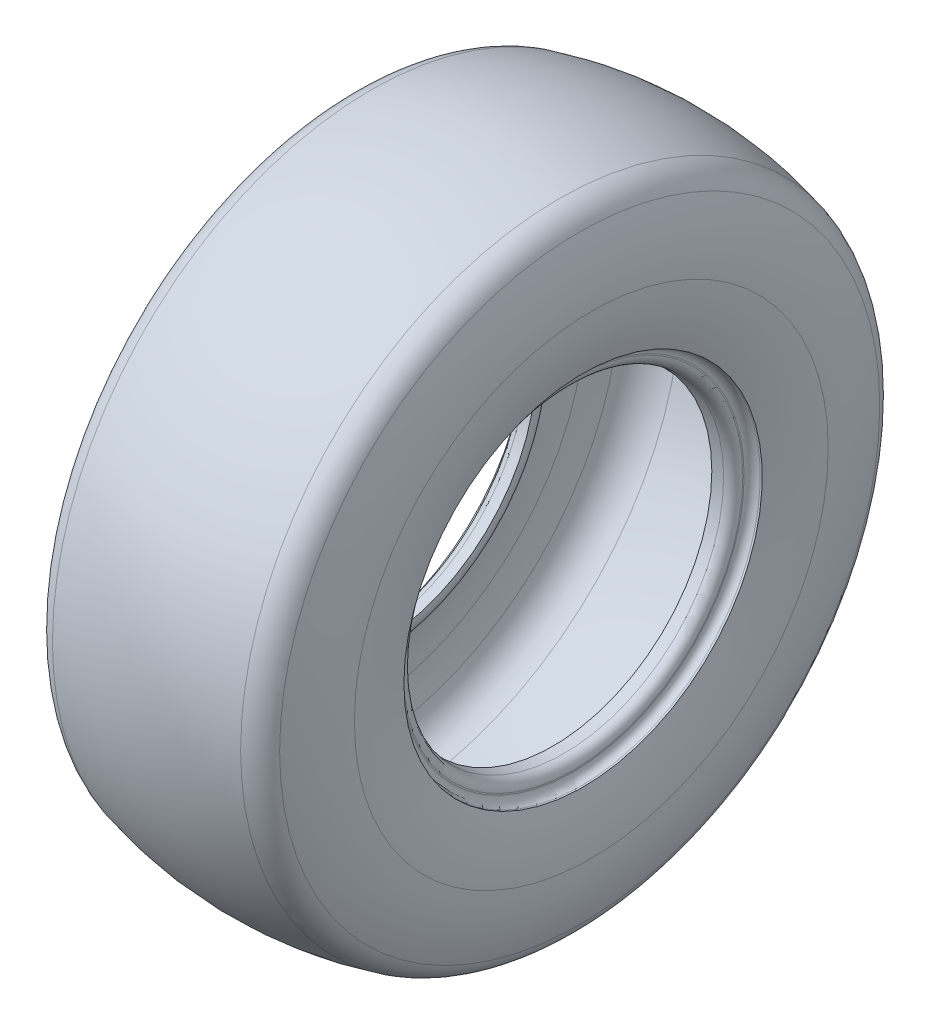
from build123d import *


with BuildPart() as part:
    # Carcass-Sketch1 → Revolve1 (revolve)
    with BuildSketch(Plane.XY):
        with BuildLine():
            Line((62.529438966, 101.092866622), (55.626, 100.488893973))
            ThreePointArc((55.626, 100.488893973), (57.017620427, 107.486009518), (61.950576009, 112.639860757))
            ThreePointArc((61.950576009, 112.639860757), (67.899546241, 118.027868878), (71.101334539, 125.387857331))
            ThreePointArc((71.101334539, 125.387857331), (72.923590457, 137.563671648), (73.533, 149.86))
            ThreePointArc((73.533, 149.86), (73.067382378, 159.765995747), (71.674635273, 169.584641632))
            ThreePointArc((71.674635273, 169.584641632), (65.12917739, 182.342637532), (52.717309301, 189.522819204))
            ThreePointArc((52.717309301, 189.522819204), (0, 195.834), (-52.717309301, 189.522819204))
            ThreePointArc((-52.717309301, 189.522819204), (-65.12917739, 182.342637532), (-71.674635273, 169.584641632))
            ThreePointArc((-71.674635273, 169.584641632), (-73.067382378, 159.765995747), (-73.533, 149.86))
            ThreePointArc((-73.533, 149.86), (-72.923590457, 137.563671648), (-71.101334539, 125.387857331))
            ThreePointArc((-71.101334539, 125.387857331), (-67.899546241, 118.027868878), (-61.950576009, 112.639860757))
            ThreePointArc((-61.950576009, 112.639860757), (-57.017620427, 107.486009518), (-55.626, 100.488893973))
            Line((-55.626, 100.488893973), (-62.529438966, 101.092866622))
            ThreePointArc((-62.529438966, 101.092866622), (-66.657711089, 103.128705137), (-68.326, 107.418702955))
            Line((-68.326, 107.418702955), (-68.326, 108.2548))
            ThreePointArc((-68.326, 108.2548), (-69.813897552, 111.846902448), (-73.406, 113.3348))
            Line((-73.406, 113.3348), (-74.676, 113.3348))
            ThreePointArc((-74.676, 113.3348), (-78.574702467, 131.412757089), (-79.883, 149.86))
            ThreePointArc((-79.883, 149.86), (-78.027065064, 170.16092799), (-72.52079236, 189.788794217))
            ThreePointArc((-72.52079236, 189.788794217), (-67.430741239, 197.187314757), (-59.516798017, 201.431867652))
            ThreePointArc((-59.516798017, 201.431867652), (0, 209.042), (59.516798017, 201.431867652))
            ThreePointArc((59.516798017, 201.431867652), (67.430741239, 197.187314757), (72.52079236, 189.788794217))
            ThreePointArc((72.52079236, 189.788794217), (78.027065064, 170.16092799), (79.883, 149.86))
            ThreePointArc((79.883, 149.86), (78.574702467, 131.412757089), (74.676, 113.3348))
            Line((74.676, 113.3348), (73.406, 113.3348))
            ThreePointArc((73.406, 113.3348), (69.813897552, 111.846902448), (68.326, 108.2548))
            Line((68.326, 108.2548), (68.326, 107.418702955))
            ThreePointArc((68.326, 107.418702955), (66.657711089, 103.128705137), (62.529438966, 101.092866622))
        make_face()
    revolve(axis=Axis((-88.99, 0, 0), (1, 0, 0)))


solid = part.part
